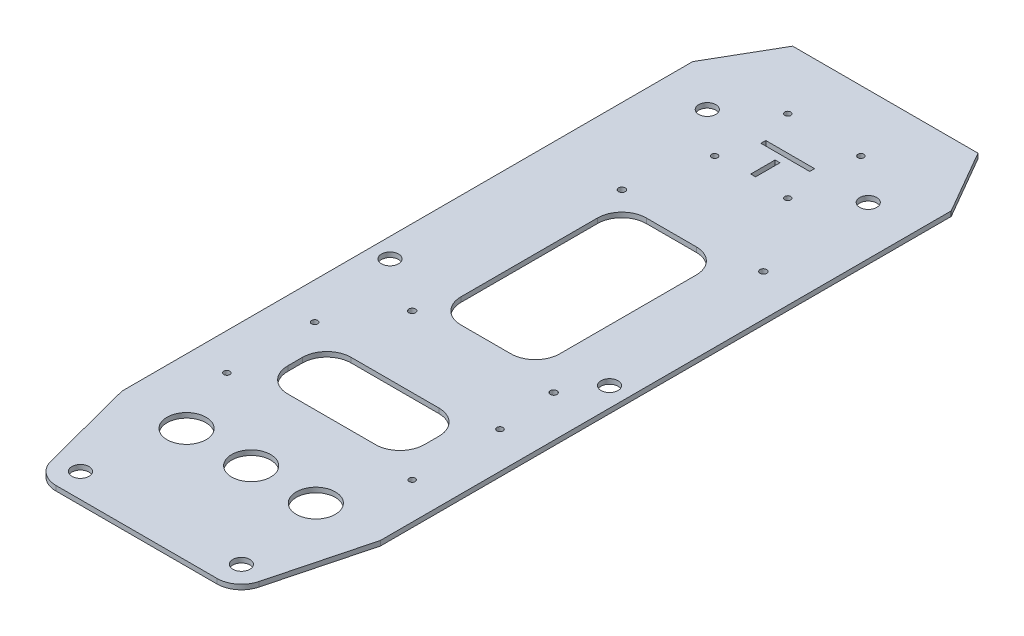
from build123d import *

# Parameters (mm, degrees)
ESQUISSE1_W             = 106
ESQUISSE1_H             = 317
ESQUISSE1_R             = 3.5
BOSS_EXTRU_1_DEPTH      = 2
ESQUISSE3_R             = 1.375
ENL_V_MAT_EXTRU_1_DEPTH = 3
CHANFREIN1_SIZE         = 15
CHANFREIN1_SIZE2        = 25.980762114
ESQUISSE4_R             = 1.25
ESQUISSE4_W             = 56
ESQUISSE4_H             = 26
ENL_V_MAT_EXTRU_2_DEPTH = 10
CONG_1_R                = 10
ESQUISSE5_W             = 40.5
ESQUISSE5_H             = 76
ENL_V_MAT_EXTRU_3_DEPTH = 10
CONG_2_R                = 10
ESQUISSE6_R             = 1.25
ESQUISSE6_W             = 20
ESQUISSE6_H             = 2
ESQUISSE6_W_2           = 2
ESQUISSE6_H_2           = 10
ENL_V_MAT_EXTRU_4_DEPTH = 10
ESQUISSE7_R             = 8
ENL_V_MAT_EXTRU_5_DEPTH = 10
ESQUISSE8_OUTSIDE_W     = 174.852
ESQUISSE8_OUTSIDE_H     = 385.852
ENL_V_MAT_EXTRU_6_DEPTH = 10
ESQUISSE9_R             = 3.5
ENL_V_MAT_EXTRU_7_DEPTH = 10


with BuildPart() as part:
    # Esquisse1 → Boss.-Extru.1 (new body)
    with BuildSketch(Plane(origin=(0, 0, 0), x_dir=(1, 0, 0), z_dir=(0, 1, 0))):
        with Locations((0, 10)):
            Rectangle(ESQUISSE1_W, ESQUISSE1_H)
        with Locations((-33, 128.5)):
            Circle(ESQUISSE1_R, mode=Mode.SUBTRACT)
        with Locations((-33, -128.5)):
            Circle(ESQUISSE1_R, mode=Mode.SUBTRACT)
        with Locations((33, 128.5)):
            Circle(ESQUISSE1_R, mode=Mode.SUBTRACT)
        with Locations((33, -128.5)):
            Circle(ESQUISSE1_R, mode=Mode.SUBTRACT)
    extrude(amount=BOSS_EXTRU_1_DEPTH)

    # Esquisse3 → Enlèv. mat.-Extru.1 (cut, through all)
    with BuildSketch(Plane(origin=(0, 2, 0), x_dir=(1, 0, 0), z_dir=(0, 1, 0))):
        with Locations((-22, -3.5)):
            Circle(ESQUISSE3_R)
        with Locations((-22, 82.5)):
            Circle(ESQUISSE3_R)
        with Locations((36, 82.5)):
            Circle(ESQUISSE3_R)
        with Locations((36, -3.5)):
            Circle(ESQUISSE3_R)
    extrude(amount=-ENL_V_MAT_EXTRU_1_DEPTH, mode=Mode.SUBTRACT)

    # Chanfrein1
    chanfrein1_edges = [part.edges().sort_by_distance(p)[0] for p in [
        (-53, 1, -168.5),
        (53, 1, -168.5),
    ]]
    chanfrein1_side = [part.faces().sort_by_distance(p)[0] for p in [
        (0, 1, -168.5),
    ]]
    chamfer(chanfrein1_edges, length=CHANFREIN1_SIZE, length2=CHANFREIN1_SIZE2, reference=chanfrein1_side[0])

    # Esquisse4 → Enlèv. mat.-Extru.2 (cut)
    with BuildSketch(Plane(origin=(0, 2, 0), x_dir=(1, 0, 0), z_dir=(0, 1, 0))):
        with Locations((38, -63.5)):
            Circle(ESQUISSE4_R)
        with Locations((38, -27.5)):
            Circle(ESQUISSE4_R)
        with Locations((-38, -63.5)):
            Circle(ESQUISSE4_R)
        with Locations((-38, -27.5)):
            Circle(ESQUISSE4_R)
        with Locations((0, -45.5)):
            Rectangle(ESQUISSE4_W, ESQUISSE4_H)
    extrude(amount=-ENL_V_MAT_EXTRU_2_DEPTH, mode=Mode.SUBTRACT)

    # Congé1
    cong_1_edges = [part.edges().sort_by_distance(p)[0] for p in [
        (-28, 1, 58.5),
        (-28, 1, 32.5),
        (28, 1, 32.5),
        (28, 1, 58.5),
    ]]
    fillet(cong_1_edges, radius=CONG_1_R)

    # Esquisse5 → Enlèv. mat.-Extru.3 (cut)
    with BuildSketch(Plane(origin=(0, 2, 0), x_dir=(1, 0, 0), z_dir=(0, 1, 0))):
        with Locations((3.25, 39.5)):
            Rectangle(ESQUISSE5_W, ESQUISSE5_H)
    extrude(amount=-ENL_V_MAT_EXTRU_3_DEPTH, mode=Mode.SUBTRACT)

    # Congé2
    cong_2_edges = [part.edges().sort_by_distance(p)[0] for p in [
        (-17, 1, -1.5),
        (-17, 1, -77.5),
        (23.5, 1, -77.5),
        (23.5, 1, -1.5),
    ]]
    fillet(cong_2_edges, radius=CONG_2_R)

    # Esquisse6 → Enlèv. mat.-Extru.4 (cut)
    with BuildSketch(Plane(origin=(0, 2, 0), x_dir=(1, 0, 0), z_dir=(0, 1, 0))):
        with Locations((-15, 113.5)):
            Circle(ESQUISSE6_R)
        with Locations((15, 113.5)):
            Circle(ESQUISSE6_R)
        with Locations((-15, 143.5)):
            Circle(ESQUISSE6_R)
        with Locations((15, 143.5)):
            Circle(ESQUISSE6_R)
        with Locations((0, 128.5)):
            Rectangle(ESQUISSE6_W, ESQUISSE6_H)
        with Locations((-0.179881847, 119.5)):
            Rectangle(ESQUISSE6_W_2, ESQUISSE6_H_2)
    extrude(amount=-ENL_V_MAT_EXTRU_4_DEPTH, mode=Mode.SUBTRACT)

    # Esquisse7 → Enlèv. mat.-Extru.5 (cut)
    with BuildSketch(Plane(origin=(0, 2, 0), x_dir=(1, 0, 0), z_dir=(0, 1, 0))):
        with Locations((0, -91.5)):
            Circle(ESQUISSE7_R)
        with Locations((-26.5, -91.5)):
            Circle(ESQUISSE7_R)
        with Locations((26.5, -91.5)):
            Circle(ESQUISSE7_R)
    extrude(amount=-ENL_V_MAT_EXTRU_5_DEPTH, mode=Mode.SUBTRACT)

    # Esquisse8 outside → Enlèv. mat.-Extru.6 (cut)
    with BuildSketch(Plane(origin=(0, 2, 0), x_dir=(1, 0, 0), z_dir=(0, 1, 0))):
        with Locations((0, 10)):
            Rectangle(ESQUISSE8_OUTSIDE_W, ESQUISSE8_OUTSIDE_H)
        with BuildLine():
            Line((38, 168.5), (-38, 168.5))
            Line((-38, 168.5), (-53, 142.519237886))
            Line((-53, 142.519237886), (-53, -91.5))
            Line((-53, -91.5), (-42.675385347, -131.027235323))
            ThreePointArc((-42.675385347, -131.027235323), (-39.11259547, -136.41430203), (-33, -138.5))
            Line((-33, -138.5), (33, -138.5))
            ThreePointArc((33, -138.5), (39.11259547, -136.41430203), (42.675385347, -131.027235323))
            Line((42.675385347, -131.027235323), (53, -91.5))
            Line((53, -91.5), (53, 142.519237886))
            Line((53, 142.519237886), (38, 168.5))
        make_face(mode=Mode.SUBTRACT)
    extrude(amount=-ENL_V_MAT_EXTRU_6_DEPTH, mode=Mode.SUBTRACT)

    # Esquisse9 → Enlèv. mat.-Extru.7 (cut)
    with BuildSketch(Plane(origin=(0, 2, 0), x_dir=(1, 0, 0), z_dir=(0, 1, 0))):
        with Locations((45, 10.423949842)):
            Circle(ESQUISSE9_R)
        with Locations((-45, 10.423949842)):
            Circle(ESQUISSE9_R)
    extrude(amount=-ENL_V_MAT_EXTRU_7_DEPTH, mode=Mode.SUBTRACT)


solid = part.part
